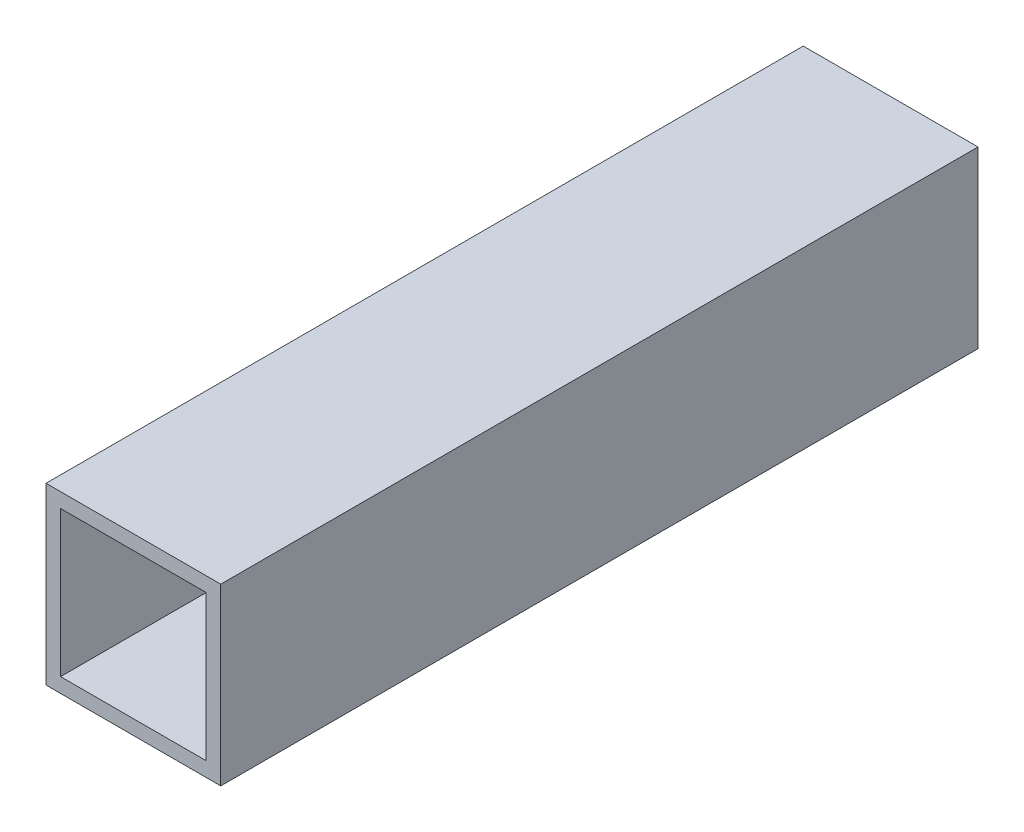
from build123d import *

# Parameters (mm, degrees)
CROQUIS2_W              = 19.05
CROQUIS2_H              = 19.05
CROQUIS2_W_2            = 15.875
CROQUIS2_H_2            = 15.875
SALIENTE_EXTRUIR1_DEPTH = 41.275


with BuildPart() as part:
    # Croquis2 → Saliente-Extruir1 (new body, symmetric)
    with BuildSketch(Plane.XY):
        Rectangle(CROQUIS2_W, CROQUIS2_H)
        Rectangle(CROQUIS2_W_2, CROQUIS2_H_2, mode=Mode.SUBTRACT)
    extrude(amount=SALIENTE_EXTRUIR1_DEPTH, both=True)


solid = part.part
